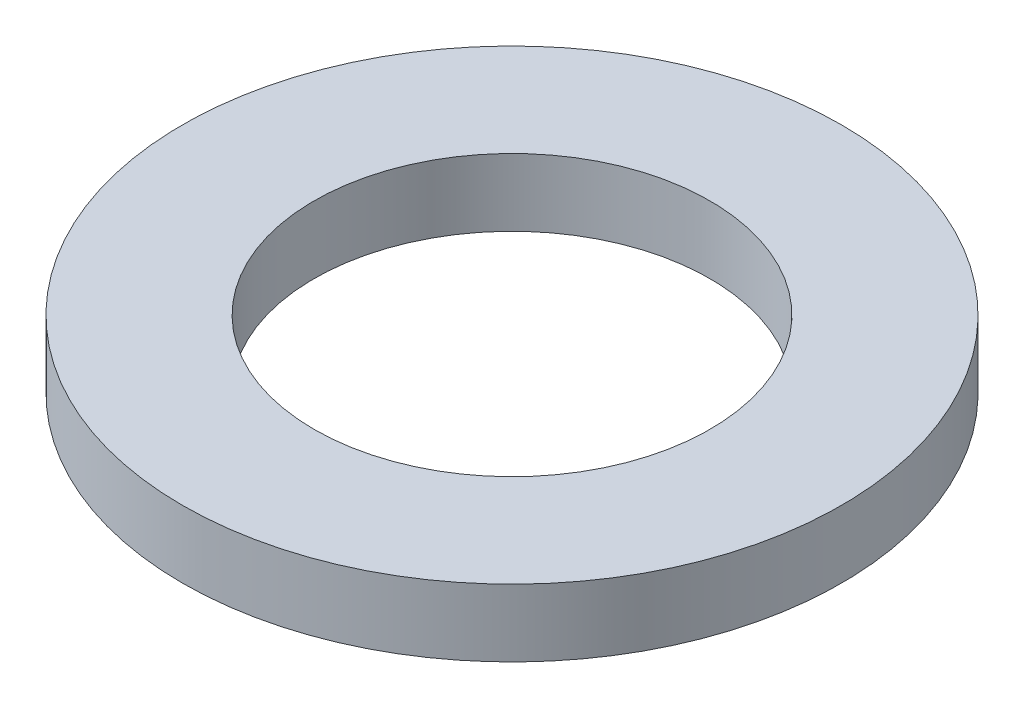
from build123d import *

# Parameters (mm, degrees)
SKETCH1_R           = 3.9751
SKETCH1_R_2         = 2.3876
BOSS_EXTRUDE1_DEPTH = 0.8128


with BuildPart() as part:
    # Sketch1 → Boss-Extrude1 (new body)
    with BuildSketch(Plane(origin=(0, 0, 0), x_dir=(1, 0, 0), z_dir=(0, 1, 0))):
        Circle(SKETCH1_R)
        Circle(SKETCH1_R_2, mode=Mode.SUBTRACT)
    extrude(amount=BOSS_EXTRUDE1_DEPTH)


solid = part.part
